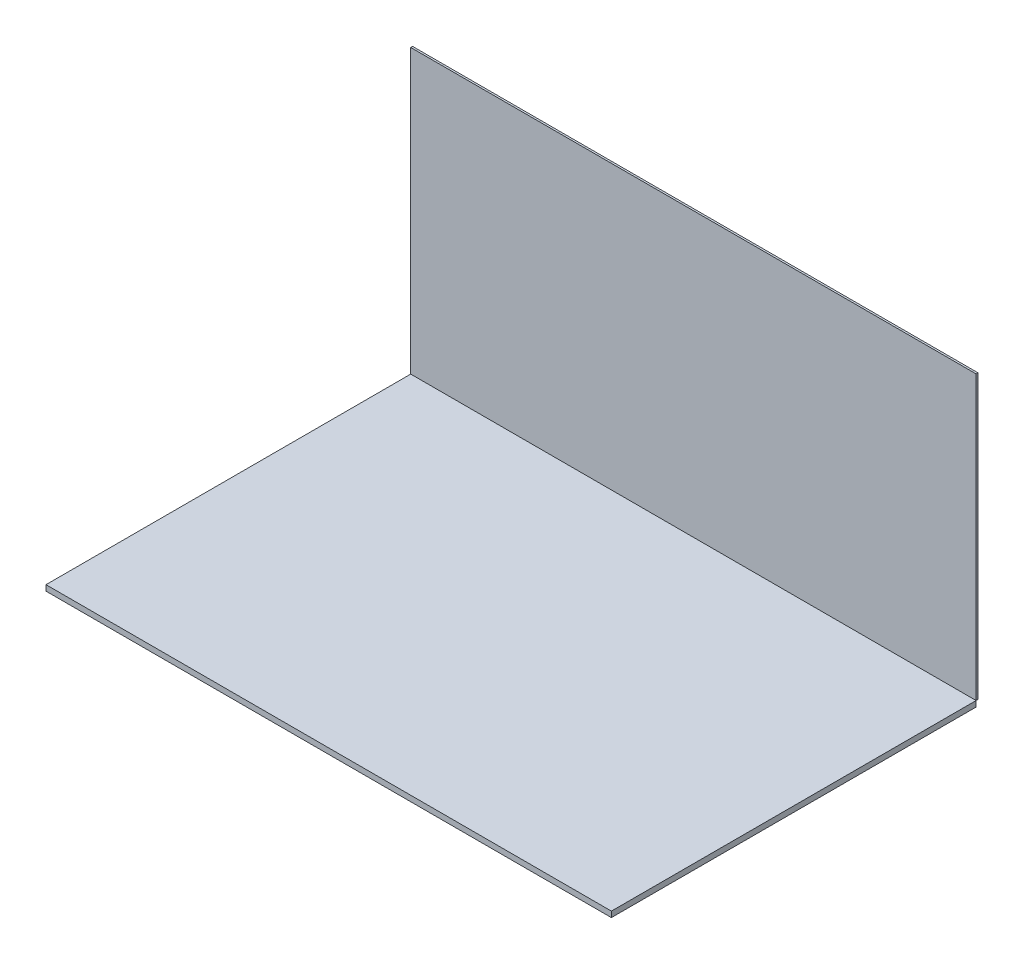
from build123d import *

# Parameters (mm, degrees)
SKETCH1_W     = 76.153195598
SKETCH1_H     = 49.123511976
FLOOR_2_DEPTH = 0.762
SKETCH5_W     = 76.153195598
SKETCH5_H     = 0.254
WALL1_DEPTH   = 38.1


with BuildPart() as part:
    # Sketch1 → Floor 2 (new body)
    with BuildSketch(Plane(origin=(0, 0, 0), x_dir=(1, 0, 0), z_dir=(0, 1, 0))):
        with Locations((-22.563909807, -4.465773816)):
            Rectangle(SKETCH1_W, SKETCH1_H)
    extrude(amount=FLOOR_2_DEPTH)


with BuildPart() as body_2:
    # Sketch5 → Wall1 (new body)
    with BuildSketch(Plane(origin=(0, 0.762, 0), x_dir=(1, 0, 0), z_dir=(0, 1, 0))):
        with Locations((-22.563909807, 20.222982172)):
            Rectangle(SKETCH5_W, SKETCH5_H)
    extrude(amount=WALL1_DEPTH)


solid = Compound([part.part, body_2.part])
